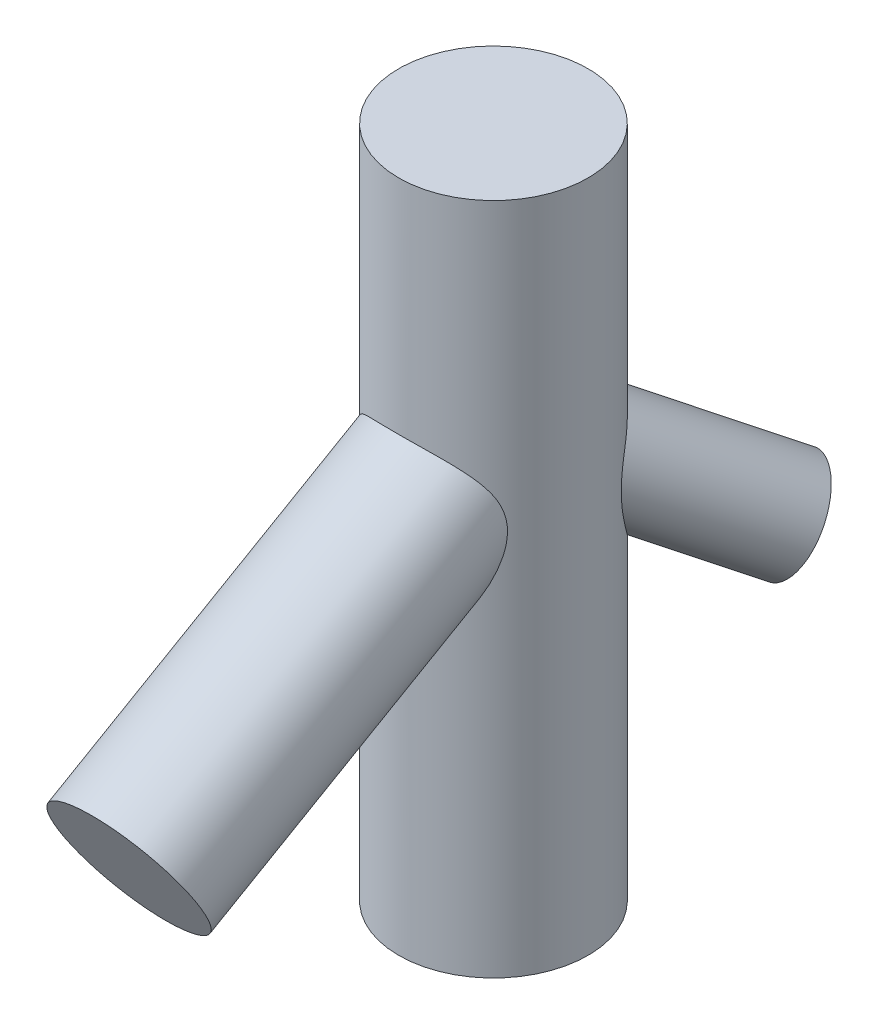
from build123d import *

# Parameters (mm, degrees)
BOSS_EXTRUDE1_DEPTH      = 30
BOSS_EXTRUDE1_DEPTH_BACK = 50
SKETCH2_R                = 11.25
BOSS_EXTRUDE2_REACH      = 80.278
BOSS_EXTRUDE2_END_RADIUS = 11.25
SKETCH4_R                = 8.75
BOSS_EXTRUDE3_REACH      = 88.818
BOSS_EXTRUDE3_END_RADIUS = 11.25
SKETCH11_R               = 6


with BuildPart() as part:
    # Sketch2 → Boss-Extrude1 (new, two sides: drawn at the far end of the back side and taken through both)
    with BuildSketch(Plane(origin=(0, 0, 0), x_dir=(1, 0, 0), z_dir=(0, 1, 0)).offset(-BOSS_EXTRUDE1_DEPTH_BACK)):
        Circle(SKETCH2_R)
    extrude(amount=BOSS_EXTRUDE1_DEPTH + BOSS_EXTRUDE1_DEPTH_BACK)

    # Boss-Extrude2: up to this cylinder (the profile starts outside it)
    boss_extrude2_end = Plane(origin=(0, -25, 0), z_dir=(0, -1, 0)) * Cylinder(BOSS_EXTRUDE2_END_RADIUS, 184.056, mode=Mode.PRIVATE)
    # Sketch4 → Boss-Extrude2 (add, up to the surface)
    with BuildSketch(Plane(origin=(0, -25, 43.301270189), x_dir=(1, 0, 0), z_dir=(0, -0.5000000000000012, 0.866025403784438)), mode=Mode.PRIVATE) as boss_extrude2_sk1:
        Circle(SKETCH4_R)
    boss_extrude2_tool1 = extrude(boss_extrude2_sk1.sketch, amount=-BOSS_EXTRUDE2_REACH, mode=Mode.PRIVATE) - boss_extrude2_end
    add(boss_extrude2_tool1.solids().sort_by_distance((0, -25, 43.30127))[0])

    # Boss-Extrude3: up to this cylinder (the profile starts outside it)
    boss_extrude3_end = Plane(origin=(0, -15, 0), z_dir=(0, -1, 0)) * Cylinder(BOSS_EXTRUDE3_END_RADIUS, 201.136, mode=Mode.PRIVATE)
    # Sketch11 → Boss-Extrude3 (add, up to the surface)
    with BuildSketch(Plane(origin=(12.990381057, -15, -22.5), x_dir=(-0.9013878188659962, -0.24019223070762985, -0.36028834606144955), z_dir=(0.43301270189222174, -0.4999999999999946, -0.7500000000000021)), mode=Mode.PRIVATE) as boss_extrude3_sk1:
        Circle(SKETCH11_R)
    boss_extrude3_tool1 = extrude(boss_extrude3_sk1.sketch, amount=-BOSS_EXTRUDE3_REACH, mode=Mode.PRIVATE) - boss_extrude3_end
    add(boss_extrude3_tool1.solids().sort_by_distance((12.990381, -15, -22.5))[0])


solid = part.part
